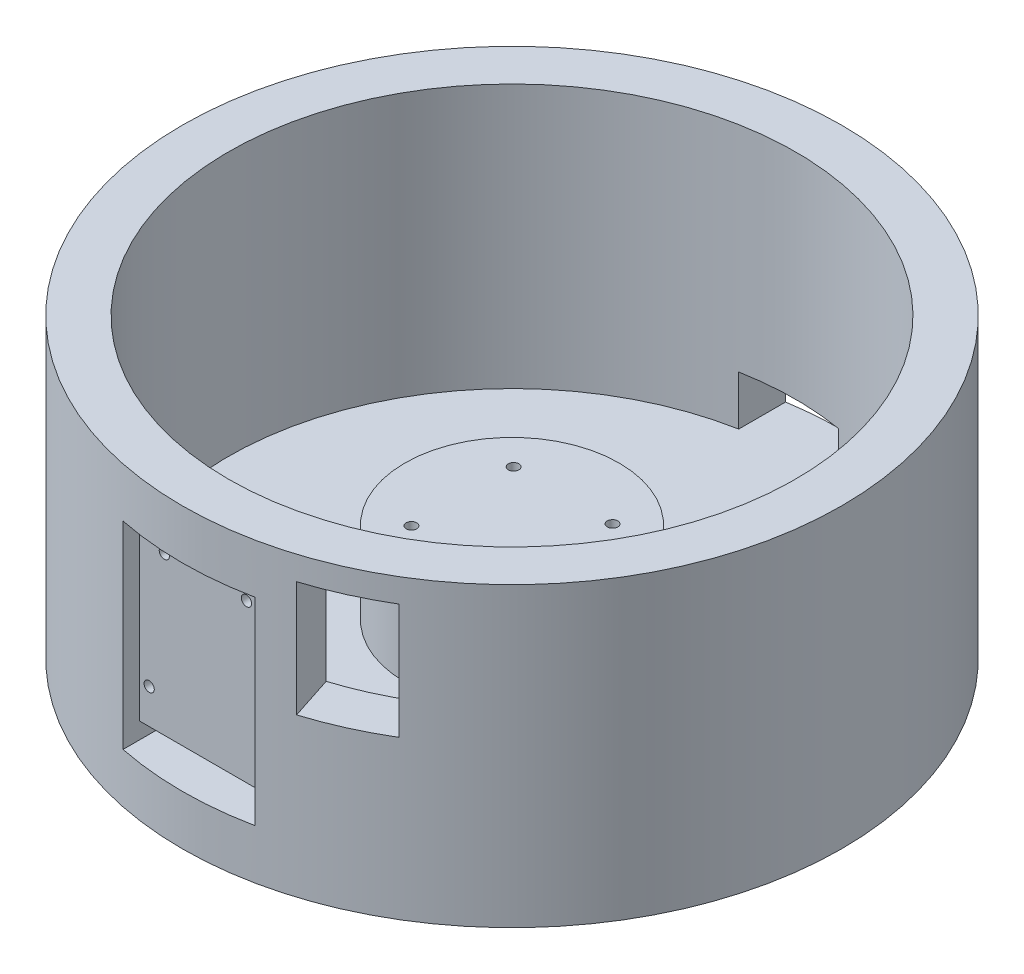
from build123d import *

# Parameters (mm, degrees)
SKETCH1_R               = 100
BOSS_EXTRUDE3_DEPTH     = 90
SKETCH4_W               = 40
SKETCH4_H               = 60
CUT_EXTRUDE2_DEPTH      = 26
CUT_EXTRUDE2_DEPTH_BACK = 12
SKETCH12_R              = 100
BOSS_EXTRUDE4_DEPTH     = 0.1
SKETCH13_R              = 86
CUT_EXTRUDE8_DEPTH      = 80
SKETCH18_R              = 32.5
BOSS_EXTRUDE5_DEPTH     = 25
SKETCH16_R              = 1.6
CUT_EXTRUDE11_DEPTH     = 91.1
SKETCH17_R              = 3
CUT_EXTRUDE12_DEPTH     = 30
SKETCH19_R              = 30
CUT_EXTRUDE13_DEPTH     = 25
SKETCH20_W              = 40
SKETCH20_H              = 5
CUT_EXTRUDE14_DEPTH     = 25
SKETCH21_R              = 1.55
CUT_EXTRUDE15_DEPTH     = 25
CUT_EXTRUDE16_DEPTH     = 35
SKETCH23_W              = 30
SKETCH23_H              = 15
CUT_EXTRUDE17_DEPTH     = 20


with BuildPart() as part:
    # Sketch1 → Boss-Extrude3 (new body)
    with BuildSketch(Plane(origin=(0, 0, 0), x_dir=(1, 0, 0), z_dir=(0, 1, 0))):
        Circle(SKETCH1_R)
    extrude(amount=BOSS_EXTRUDE3_DEPTH)

    # Sketch4 → Cut-Extrude2 (cut, two sides)
    with BuildSketch(Plane.XY.offset(105)) as cut_extrude2_sk:
        with Locations((0, 45)):
            Rectangle(SKETCH4_W, SKETCH4_H)
    extrude(amount=CUT_EXTRUDE2_DEPTH, mode=Mode.SUBTRACT)
    extrude(cut_extrude2_sk.sketch, amount=-CUT_EXTRUDE2_DEPTH_BACK, mode=Mode.SUBTRACT)

    # Sketch12 → Boss-Extrude4 (add)
    with BuildSketch(Plane.XZ):
        Circle(SKETCH12_R)
    extrude(amount=BOSS_EXTRUDE4_DEPTH)

    # Sketch13 → Cut-Extrude8 (cut)
    with BuildSketch(Plane(origin=(0, 90, 0), x_dir=(1, 0, 0), z_dir=(0, 1, 0))):
        Circle(SKETCH13_R)
    extrude(amount=-CUT_EXTRUDE8_DEPTH, mode=Mode.SUBTRACT)

    # Sketch18 → Boss-Extrude5 (add)
    with BuildSketch(Plane(origin=(0, 10, 0), x_dir=(1, 0, 0), z_dir=(0, 1, 0))):
        Circle(SKETCH18_R)
    extrude(amount=BOSS_EXTRUDE5_DEPTH)

    # Sketch16 → Cut-Extrude11 (cut, through all)
    with BuildSketch(Plane.XZ.offset(0.1)):
        with Locations((-15, 15.5)):
            Circle(SKETCH16_R)
        with Locations((15, 15.5)):
            Circle(SKETCH16_R)
        with Locations((15, -15.5)):
            Circle(SKETCH16_R)
        with Locations((-15, -15.5)):
            Circle(SKETCH16_R)
    extrude(amount=-CUT_EXTRUDE11_DEPTH, mode=Mode.SUBTRACT)

    # Sketch17 → Cut-Extrude12 (cut)
    with BuildSketch(Plane.XZ.offset(0.1)):
        with Locations((-15, 15.5)):
            Circle(SKETCH17_R)
        with Locations((15, 15.5)):
            Circle(SKETCH17_R)
        with Locations((-15, -15.5)):
            Circle(SKETCH17_R)
        with Locations((15, -15.5)):
            Circle(SKETCH17_R)
    extrude(amount=-CUT_EXTRUDE12_DEPTH, mode=Mode.SUBTRACT)

    # Sketch19 → Cut-Extrude13 (cut)
    with BuildSketch(Plane.XZ.offset(0.1)):
        Circle(SKETCH19_R)
    extrude(amount=-CUT_EXTRUDE13_DEPTH, mode=Mode.SUBTRACT)

    # Sketch20 → Cut-Extrude14 (cut)
    with BuildSketch(Plane.XY.offset(93)):
        with Locations((0, 17.5)):
            Rectangle(SKETCH20_W, SKETCH20_H)
    extrude(amount=-CUT_EXTRUDE14_DEPTH, mode=Mode.SUBTRACT)

    # Sketch21 → Cut-Extrude15 (cut)
    with BuildSketch(Plane.XY.offset(93)):
        with Locations((12.45, 67.8)):
            Circle(SKETCH21_R)
        with Locations((-12.45, 67.8)):
            Circle(SKETCH21_R)
        with Locations((-17.05, 30.54)):
            Circle(SKETCH21_R)
        with Locations((17.05, 30.54)):
            Circle(SKETCH21_R)
    extrude(amount=-CUT_EXTRUDE15_DEPTH, mode=Mode.SUBTRACT)

    # Sketch22 → Cut-Extrude16 (cut)
    with BuildSketch(Plane(origin=(22.204096953, 47.794122581, -296.404157649), x_dir=(1, 0, 0), z_dir=(0, 1, 0))):
        Polygon((-6.791929493, -346.959107226), (12.404969277, -405.762485644), (37.058002756, -394.3841625), (3.953655983, -342.212063172), align=None)
    extrude(amount=CUT_EXTRUDE16_DEPTH, mode=Mode.SUBTRACT)

    # Sketch23 → Cut-Extrude17 (cut)
    with BuildSketch(Plane.XY.offset(-100)):
        with Locations((-0.77861777, 17.5)):
            Rectangle(SKETCH23_W, SKETCH23_H)
    extrude(amount=CUT_EXTRUDE17_DEPTH, mode=Mode.SUBTRACT)


solid = part.part
